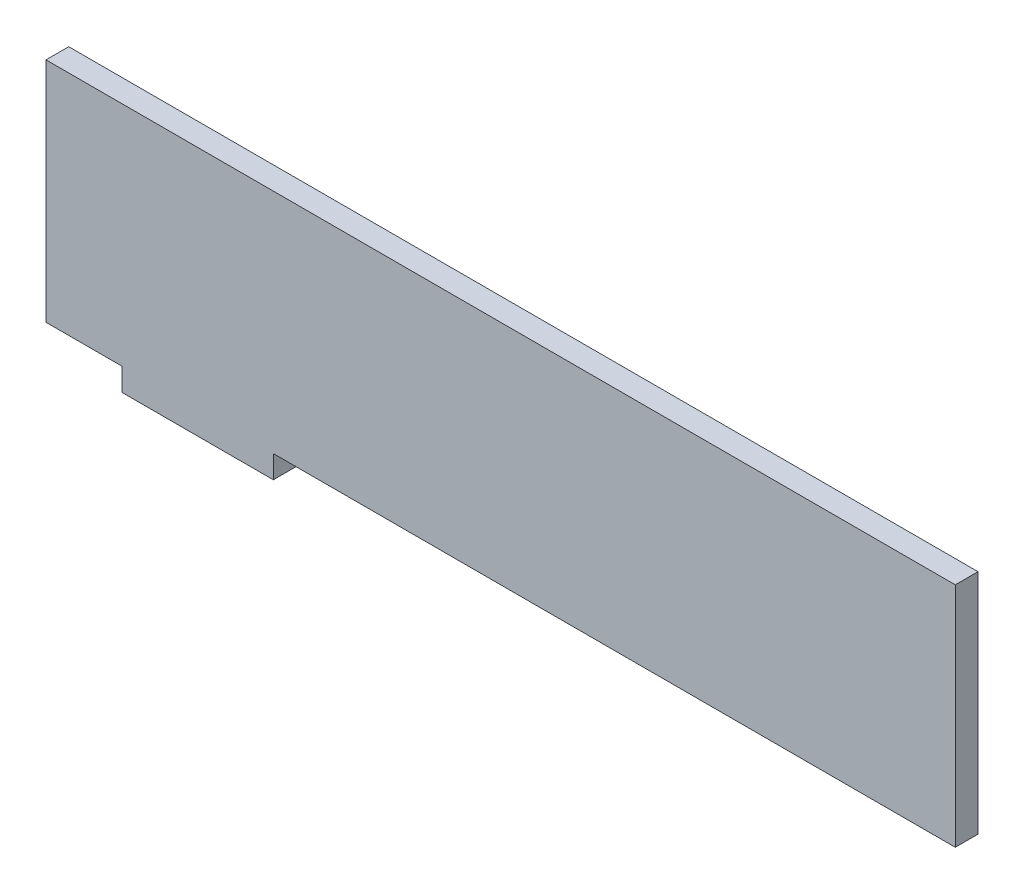
from build123d import *

# Parameters (mm, degrees)
BOSS_EXTRUDE1_DEPTH = 3


with BuildPart() as part:
    # Sketch1 → Boss-Extrude1 (new body)
    with BuildSketch(Plane.XY):
        Polygon((-25, -13), (-35, -13), (-35, 17), (85, 17), (85, -13), (-5, -13), (-5, -16), (-25, -16), align=None)
    extrude(amount=BOSS_EXTRUDE1_DEPTH)


solid = part.part
